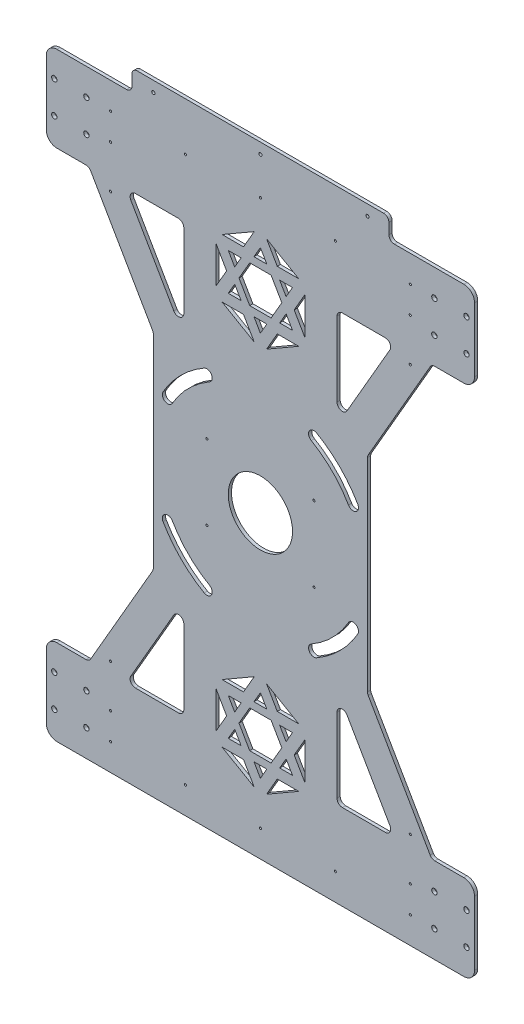
from build123d import *

# Parameters (mm, degrees)
EXTRUDE_1_DEPTH      = 3
SKETCH_3_R           = 2.5
CUT_EXTRUDE_1_DEPTH  = 3
SKETCH_5_R           = 1.5
CUT_EXTRUDE_2_DEPTH  = 3
CUT_EXTRUDE_3_DEPTH  = 3
CUT_EXTRUDE_4_DEPTH  = 10
SKETCH_13_R          = 1
CUT_EXTRUDE_6_DEPTH  = 10
SKETCH_14_R          = 30
CUT_EXTRUDE_7_DEPTH  = 10
SKETCH_15_R          = 1
CUT_EXTRUDE_8_DEPTH  = 10
SKETCH_20_R          = 1
CUT_EXTRUDE_10_DEPTH = 10
CUT_EXTRUDE_11_DEPTH = 3


with BuildPart() as part:
    # 草图2 → 凸台-拉伸1 (new body)
    with BuildSketch(Plane.XY):
        with BuildLine():
            Line((-190, 280), (-125, 280))
            ThreePointArc((-125, 280), (-121.464466094, 281.464466094), (-120, 285))
            Line((-120, 285), (-120, 295))
            ThreePointArc((-120, 295), (-118.535533906, 298.535533906), (-115, 300))
            Line((-115, 300), (115, 300))
            ThreePointArc((115, 300), (118.535533906, 298.535533906), (120, 295))
            Line((120, 295), (120, 285))
            ThreePointArc((120, 285), (121.464466094, 281.464466094), (125, 280))
            Line((125, 280), (190, 280))
            ThreePointArc((190, 280), (197.071067812, 277.071067812), (200, 270))
            Line((200, 270), (200, 210))
            ThreePointArc((200, 210), (197.071067812, 202.928932188), (190, 200))
            Line((190, 200), (162.886751346, 200))
            ThreePointArc((162.886751346, 200), (160.386751346, 199.330127019), (158.556624327, 197.5))
            Line((158.556624327, 197.5), (100.669872981, 97.237205584))
            ThreePointArc((100.669872981, 97.237205584), (100.170370869, 96.031300809), (100, 94.737205584))
            Line((100, 94.737205584), (100, -94.737205584))
            ThreePointArc((100, -94.737205584), (100.170370869, -96.031300809), (100.669872981, -97.237205584))
            Line((100.669872981, -97.237205584), (158.556624327, -197.5))
            ThreePointArc((158.556624327, -197.5), (160.386751346, -199.330127019), (162.886751346, -200))
            Line((162.886751346, -200), (190, -200))
            ThreePointArc((190, -200), (197.071067812, -202.928932188), (200, -210))
            Line((200, -210), (200, -270))
            ThreePointArc((200, -270), (197.071067812, -277.071067812), (190, -280))
            Line((190, -280), (-190, -280))
            ThreePointArc((-190, -280), (-197.071067812, -277.071067812), (-200, -270))
            Line((-200, -270), (-200, -210))
            ThreePointArc((-200, -210), (-197.071067812, -202.928932188), (-190, -200))
            Line((-190, -200), (-162.886751346, -200))
            ThreePointArc((-162.886751346, -200), (-160.386751346, -199.330127019), (-158.556624327, -197.5))
            Line((-158.556624327, -197.5), (-100.669872981, -97.237205584))
            ThreePointArc((-100.669872981, -97.237205584), (-100.170370869, -96.031300809), (-100, -94.737205584))
            Line((-100, -94.737205584), (-100, 94.737205584))
            ThreePointArc((-100, 94.737205584), (-100.170370869, 96.031300809), (-100.669872981, 97.237205584))
            Line((-100.669872981, 97.237205584), (-158.556624327, 197.5))
            ThreePointArc((-158.556624327, 197.5), (-160.386751346, 199.330127019), (-162.886751346, 200))
            Line((-162.886751346, 200), (-190, 200))
            ThreePointArc((-190, 200), (-197.071067812, 202.928932188), (-200, 210))
            Line((-200, 210), (-200, 270))
            ThreePointArc((-200, 270), (-197.071067812, 277.071067812), (-190, 280))
        make_face()
    extrude(amount=EXTRUDE_1_DEPTH)

    # 草图3 → 切除-拉伸1 (cut)
    with BuildSketch(Plane.XY.offset(3)):
        with Locations((-162.5, -225)):
            Circle(SKETCH_3_R)
        with Locations((-192.5, -225)):
            Circle(SKETCH_3_R)
        with Locations((-192.5, -255)):
            Circle(SKETCH_3_R)
        with Locations((-162.5, -255)):
            Circle(SKETCH_3_R)
        with Locations((-162.5, 255)):
            Circle(SKETCH_3_R)
        with Locations((-192.5, 255)):
            Circle(SKETCH_3_R)
        with Locations((-192.5, 225)):
            Circle(SKETCH_3_R)
        with Locations((-162.5, 225)):
            Circle(SKETCH_3_R)
        with Locations((192.5, -255)):
            Circle(SKETCH_3_R)
        with Locations((192.5, -225)):
            Circle(SKETCH_3_R)
        with Locations((162.5, -225)):
            Circle(SKETCH_3_R)
        with Locations((162.5, -255)):
            Circle(SKETCH_3_R)
        with Locations((162.5, 225)):
            Circle(SKETCH_3_R)
        with Locations((192.5, 225)):
            Circle(SKETCH_3_R)
        with Locations((192.5, 255)):
            Circle(SKETCH_3_R)
        with Locations((162.5, 255)):
            Circle(SKETCH_3_R)
    extrude(amount=-CUT_EXTRUDE_1_DEPTH, mode=Mode.SUBTRACT)

    # 草图5 → 切除-拉伸2 (cut)
    with BuildSketch(Plane.XY.offset(3)):
        with Locations((0, 290)):
            Circle(SKETCH_5_R)
        with Locations((100, 290)):
            Circle(SKETCH_5_R)
        with Locations((-100, 290)):
            Circle(SKETCH_5_R)
    extrude(amount=-CUT_EXTRUDE_2_DEPTH, mode=Mode.SUBTRACT)

    # 草图8 → 切除-拉伸3 (cut)
    with BuildSketch(Plane.XY.offset(3)):
        Polygon((20, 180), (10, 197.320508076), (-10, 197.320508076), (-20, 180), (-10, 162.679491924), (10, 162.679491924), align=None)
        Polygon((24, 173.07179677), (30, 162.679491924), (18, 162.679491924), align=None)
        Polygon((18, 197.320508076), (24, 186.92820323), (30, 197.320508076), align=None)
        Polygon((0, 214.641016151), (6, 204.248711306), (-6, 204.248711306), align=None)
        Polygon((0, 145.358983849), (6, 155.751288694), (-6, 155.751288694), align=None)
        Polygon((-24, 186.92820323), (-18, 197.320508076), (-30, 197.320508076), align=None)
        Polygon((-30, 162.679491924), (-24, 173.07179677), (-18, 162.679491924), align=None)
        Polygon((5.773502692, 224.641016151), (15.773502692, 207.320508076), (35.773502692, 207.320508076), align=None)
        Polygon((41.547005384, 197.320508076), (41.547005384, 162.679491924), (31.547005384, 180), align=None)
        Polygon((-41.547005384, 162.679491924), (-41.547005384, 197.320508076), (-31.547005384, 180), align=None)
        Polygon((-5.773502692, 135.358983849), (-15.773502692, 152.679491924), (-35.773502692, 152.679491924), align=None)
        Polygon((35.773502692, 152.679491924), (5.773502692, 135.358983849), (15.773502692, 152.679491924), align=None)
        Polygon((-35.773502692, 207.320508076), (-5.773502692, 224.641016151), (-15.773502692, 207.320508076), align=None)
        Polygon((-5.773502692, -224.641016151), (-15.773502692, -207.320508076), (-35.773502692, -207.320508076), align=None)
        Polygon((5.773502692, -135.358983849), (15.773502692, -152.679491924), (35.773502692, -152.679491924), align=None)
        Polygon((-35.773502692, -152.679491924), (-5.773502692, -135.358983849), (-15.773502692, -152.679491924), align=None)
        Polygon((-41.547005384, -197.320508076), (-31.547005384, -180), (-41.547005384, -162.679491924), align=None)
        Polygon((41.547005384, -162.679491924), (31.547005384, -180), (41.547005384, -197.320508076), align=None)
        Polygon((35.773502692, -207.320508076), (5.773502692, -224.641016151), (15.773502692, -207.320508076), align=None)
        Polygon((-24, -173.07179677), (-18, -162.679491924), (-30, -162.679491924), align=None)
        Polygon((-30, -197.320508076), (-24, -186.92820323), (-18, -197.320508076), align=None)
        Polygon((-6, -155.751288694), (0, -145.358983849), (6, -155.751288694), align=None)
        Polygon((6, -204.248711306), (-6, -204.248711306), (0, -214.641016151), align=None)
        Polygon((30, -197.320508076), (18, -197.320508076), (24, -186.92820323), align=None)
        Polygon((18, -162.679491924), (24, -173.07179677), (30, -162.679491924), align=None)
        Polygon((10, -162.679491924), (20, -180), (10, -197.320508076), (-10, -197.320508076), (-20, -180), (-10, -162.679491924), align=None)
    extrude(amount=-CUT_EXTRUDE_3_DEPTH, mode=Mode.SUBTRACT)

    # 草图9 → 切除-拉伸4 (cut)
    with BuildSketch(Plane.XY.offset(3)):
        with BuildLine():
            Line((71.547005384, 195), (71.547005384, 125.455173281))
            ThreePointArc((71.547005384, 125.455173281), (75.252910158, 120.62554415), (80.877132403, 122.955173281))
            Line((80.877132403, 122.955173281), (121.02885683, 192.5))
            ThreePointArc((121.02885683, 192.5), (121.02885683, 197.5), (116.698729811, 200))
            Line((116.698729811, 200), (76.547005384, 200))
            ThreePointArc((76.547005384, 200), (73.011471478, 198.535533906), (71.547005384, 195))
        make_face()
        with BuildLine():
            Line((-116.698729811, 200), (-76.547005384, 200))
            ThreePointArc((-76.547005384, 200), (-73.011471478, 198.535533906), (-71.547005384, 195))
            Line((-71.547005384, 195), (-71.547005384, 125.455173281))
            ThreePointArc((-71.547005384, 125.455173281), (-75.252910158, 120.62554415), (-80.877132403, 122.955173281))
            Line((-80.877132403, 122.955173281), (-121.02885683, 192.5))
            ThreePointArc((-121.02885683, 192.5), (-121.02885683, 197.5), (-116.698729811, 200))
        make_face()
        with BuildLine():
            Line((-71.547005384, -195), (-71.547005384, -125.455173281))
            ThreePointArc((-71.547005384, -125.455173281), (-75.252910158, -120.62554415), (-80.877132403, -122.955173281))
            Line((-80.877132403, -122.955173281), (-121.02885683, -192.5))
            ThreePointArc((-121.02885683, -192.5), (-121.02885683, -197.5), (-116.698729811, -200))
            Line((-116.698729811, -200), (-76.547005384, -200))
            ThreePointArc((-76.547005384, -200), (-73.011471478, -198.535533906), (-71.547005384, -195))
        make_face()
        with BuildLine():
            Line((116.698729811, -200), (76.547005384, -200))
            ThreePointArc((76.547005384, -200), (73.011471478, -198.535533906), (71.547005384, -195))
            Line((71.547005384, -195), (71.547005384, -125.455173281))
            ThreePointArc((71.547005384, -125.455173281), (75.252910158, -120.62554415), (80.877132403, -122.955173281))
            Line((80.877132403, -122.955173281), (121.02885683, -192.5))
            ThreePointArc((121.02885683, -192.5), (121.02885683, -197.5), (116.698729811, -200))
        make_face()
    extrude(amount=-CUT_EXTRUDE_4_DEPTH, mode=Mode.SUBTRACT)

    # 草图13 → 切除-拉伸6 (cut)
    with BuildSketch(Plane.XY.offset(3)):
        with Locations((0, 255)):
            Circle(SKETCH_13_R)
        with Locations((70, 255)):
            Circle(SKETCH_13_R)
        with Locations((140, 255)):
            Circle(SKETCH_13_R)
        with Locations((-140, 255)):
            Circle(SKETCH_13_R)
        with Locations((-70, 255)):
            Circle(SKETCH_13_R)
        with Locations((-70, -255)):
            Circle(SKETCH_13_R)
        with Locations((-140, -255)):
            Circle(SKETCH_13_R)
        with Locations((140, -255)):
            Circle(SKETCH_13_R)
        with Locations((70, -255)):
            Circle(SKETCH_13_R)
        with Locations((0, -255)):
            Circle(SKETCH_13_R)
    extrude(amount=-CUT_EXTRUDE_6_DEPTH, mode=Mode.SUBTRACT)

    # 草图14 → 切除-拉伸7 (cut)
    with BuildSketch(Plane.XY.offset(3)):
        Circle(SKETCH_14_R)
    extrude(amount=-CUT_EXTRUDE_7_DEPTH, mode=Mode.SUBTRACT)

    # 草图15 → 切除-拉伸8 (cut)
    with BuildSketch(Plane.XY.offset(3)):
        with Locations((-140, 230)):
            Circle(SKETCH_15_R)
        with Locations((-140, 190)):
            Circle(SKETCH_15_R)
        with Locations((140, 190)):
            Circle(SKETCH_15_R)
        with Locations((140, 230)):
            Circle(SKETCH_15_R)
        with Locations((140, -230)):
            Circle(SKETCH_15_R)
        with Locations((140, -190)):
            Circle(SKETCH_15_R)
        with Locations((-140, -190)):
            Circle(SKETCH_15_R)
        with Locations((-140, -230)):
            Circle(SKETCH_15_R)
    extrude(amount=-CUT_EXTRUDE_8_DEPTH, mode=Mode.SUBTRACT)

    # 草图20 → 切除-拉伸10 (cut)
    with BuildSketch(Plane.XY.offset(3)):
        with Locations((-50, 35)):
            Circle(SKETCH_20_R)
        with Locations((-50, -35)):
            Circle(SKETCH_20_R)
        with Locations((50, -35)):
            Circle(SKETCH_20_R)
        with Locations((50, 35)):
            Circle(SKETCH_20_R)
    extrude(amount=-CUT_EXTRUDE_10_DEPTH, mode=Mode.SUBTRACT)

    # 草图22 → 切除-拉伸11 (cut)
    with BuildSketch(Plane.XY.offset(3)):
        with BuildLine():
            ThreePointArc((90.932667397, 52.5), (74.246212025, 74.246212025), (52.5, 90.932667397))
            ThreePointArc((52.5, 90.932667397), (45.669872981, 89.102540378), (47.5, 82.27241336))
            ThreePointArc((47.5, 82.27241336), (67.175144213, 67.175144213), (82.27241336, 47.5))
            ThreePointArc((82.27241336, 47.5), (89.102540378, 45.669872981), (90.932667397, 52.5))
        make_face()
        with BuildLine():
            ThreePointArc((47.5, -82.27241336), (67.175144213, -67.175144213), (82.27241336, -47.5))
            ThreePointArc((82.27241336, -47.5), (89.102540378, -45.669872981), (90.932667397, -52.5))
            ThreePointArc((90.932667397, -52.5), (74.246212025, -74.246212025), (52.5, -90.932667397))
            ThreePointArc((52.5, -90.932667397), (45.669872981, -89.102540378), (47.5, -82.27241336))
        make_face()
        with BuildLine():
            ThreePointArc((-82.27241336, -47.5), (-67.175144213, -67.175144213), (-47.5, -82.27241336))
            ThreePointArc((-47.5, -82.27241336), (-45.669872981, -89.102540378), (-52.5, -90.932667397))
            ThreePointArc((-52.5, -90.932667397), (-74.246212025, -74.246212025), (-90.932667397, -52.5))
            ThreePointArc((-90.932667397, -52.5), (-89.102540378, -45.669872981), (-82.27241336, -47.5))
        make_face()
        with BuildLine():
            ThreePointArc((-47.5, 82.27241336), (-67.175144213, 67.175144213), (-82.27241336, 47.5))
            ThreePointArc((-82.27241336, 47.5), (-89.102540378, 45.669872981), (-90.932667397, 52.5))
            ThreePointArc((-90.932667397, 52.5), (-74.246212025, 74.246212025), (-52.5, 90.932667397))
            ThreePointArc((-52.5, 90.932667397), (-45.669872981, 89.102540378), (-47.5, 82.27241336))
        make_face()
    extrude(amount=-CUT_EXTRUDE_11_DEPTH, mode=Mode.SUBTRACT)


solid = part.part
